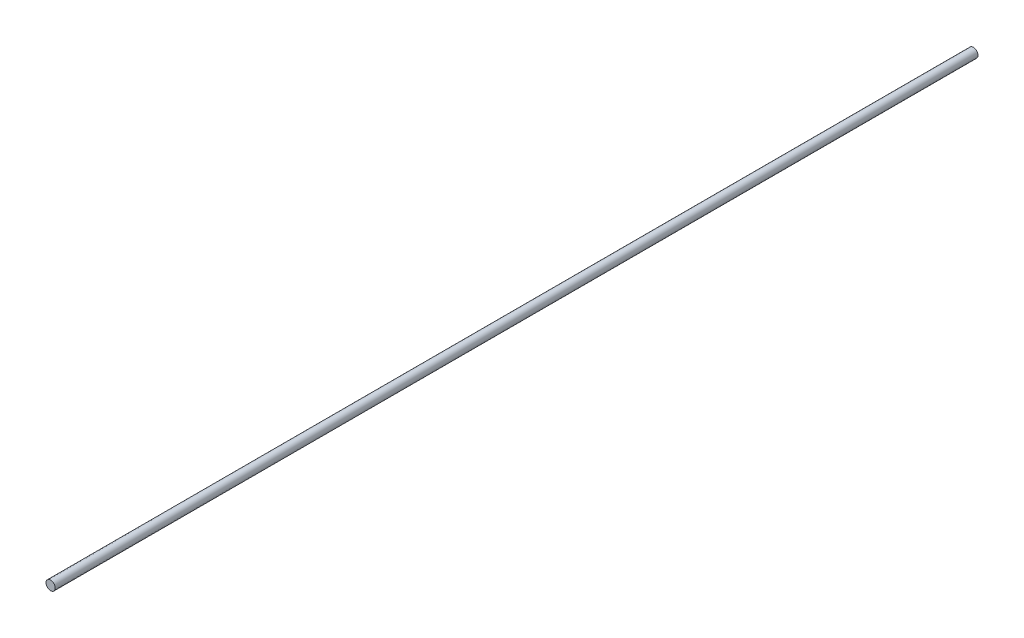
from build123d import *

# Parameters (mm, degrees)
SKETCH1_R           = 4
BOSS_EXTRUDE1_DEPTH = 400


with BuildPart() as part:
    # Sketch1 → Boss-Extrude1 (new body, symmetric)
    with BuildSketch(Plane.XY):
        Circle(SKETCH1_R)
    extrude(amount=BOSS_EXTRUDE1_DEPTH, both=True)


solid = part.part
